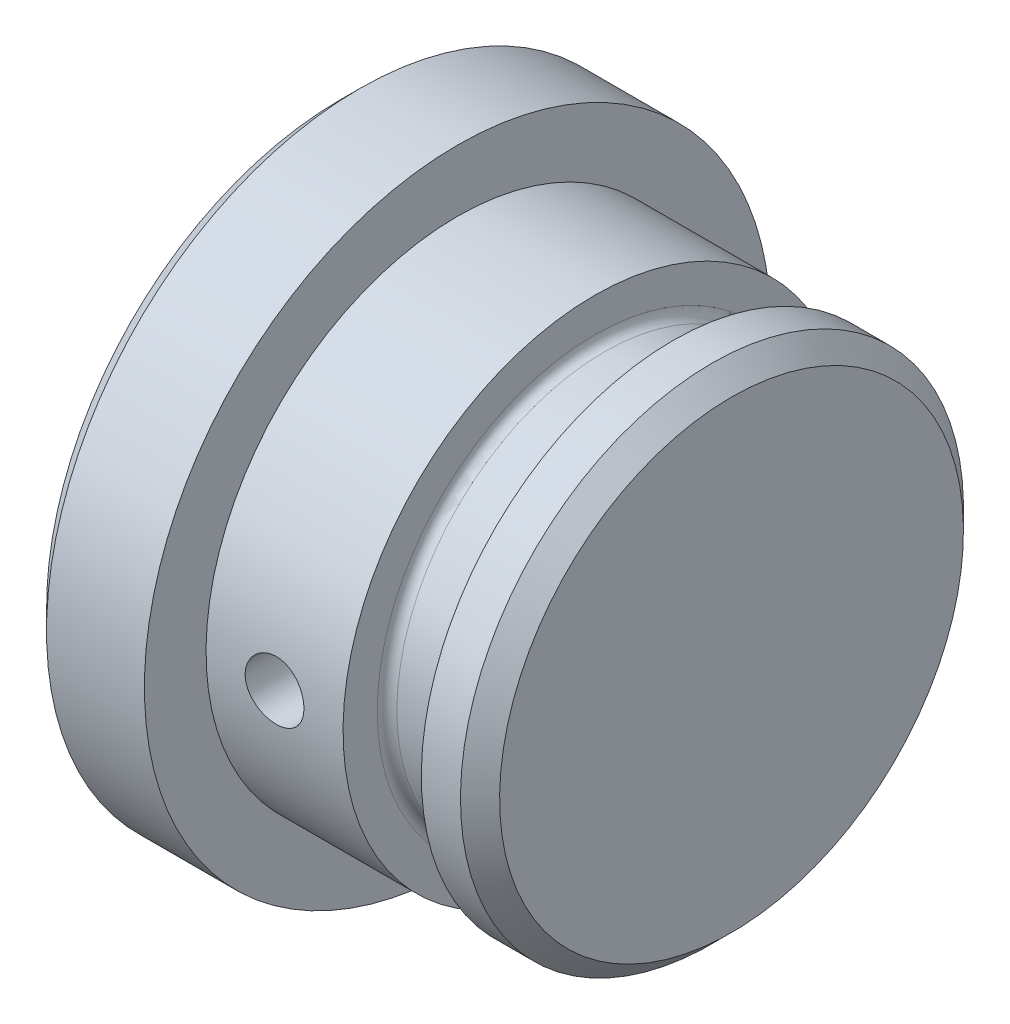
from build123d import *

# Parameters (mm, degrees)
ESQUISSE2_R                  = 1.5
ENL_V_MAT_EXTRU_1_DEPTH      = 17
ENL_V_MAT_EXTRU_1_DEPTH_BACK = 17


with BuildPart() as part:
    # Esquisse1 → Révolution1 (revolve)
    with BuildSketch(Plane.XY):
        with BuildLine():
            Line((-170, 19.5), (-175, 19.5))
            Line((-175, 19.5), (-176, 18.5))
            Line((-176, 18.5), (-176, 3.5))
            Line((-176, 3.5), (-156, 3.5))
            Line((-156, 3.5), (-156, 15.35))
            Line((-156, 15.35), (-157, 16.35))
            Line((-157, 16.35), (-159, 16.35))
            Line((-159, 16.35), (-159, 14.6))
            ThreePointArc((-159, 14.6), (-159.146446609, 14.246446609), (-159.5, 14.1))
            Line((-159.5, 14.1), (-162.5, 14.1))
            ThreePointArc((-162.5, 14.1), (-162.853553391, 14.246446609), (-163, 14.6))
            Line((-163, 14.6), (-163, 16.35))
            Line((-163, 16.35), (-170, 16.35))
            Line((-170, 16.35), (-170, 19.5))
        make_face()
    revolve(axis=Axis((-170, 3.5, 0), (-1, 0, 0)))

    # Esquisse2 → Enlèv. mat.-Extru.1 (cut, two sides)
    with BuildSketch(Plane.XY) as enl_v_mat_extru_1_sk:
        with Locations((-166.5, 3.5)):
            Circle(ESQUISSE2_R)
    extrude(amount=ENL_V_MAT_EXTRU_1_DEPTH, mode=Mode.SUBTRACT)
    extrude(enl_v_mat_extru_1_sk.sketch, amount=-ENL_V_MAT_EXTRU_1_DEPTH_BACK, mode=Mode.SUBTRACT)


solid = part.part
